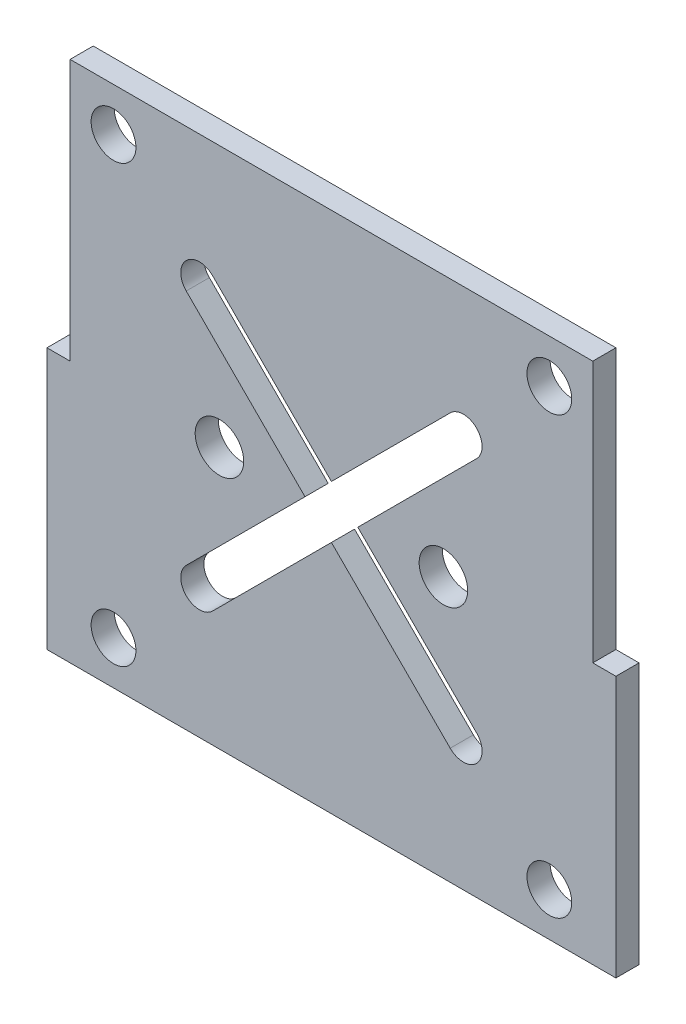
from build123d import *

# Parameters (mm, degrees)
SKETCH1_W           = 70
SKETCH1_H           = 70
SKETCH1_R           = 3
SKETCH1_R_2         = 3.25
BOSS_EXTRUDE1_DEPTH = 3.1
SKETCH2_W           = 3.1
SKETCH2_H           = 35
BOSS_EXTRUDE2_DEPTH = 3.1
CUT_EXTRUDE1_DEPTH  = 4.1


with BuildPart() as part:
    # Sketch1 → Boss-Extrude1 (new body)
    with BuildSketch(Plane.XY):
        Rectangle(SKETCH1_W, SKETCH1_H)
        with Locations((-29.185832393, 29.185832393)):
            Circle(SKETCH1_R, mode=Mode.SUBTRACT)
        with Locations((29.185832393, 29.185832393)):
            Circle(SKETCH1_R, mode=Mode.SUBTRACT)
        with Locations((29.185832393, -29.185832393)):
            Circle(SKETCH1_R, mode=Mode.SUBTRACT)
        with Locations((-29.185832393, -29.185832393)):
            Circle(SKETCH1_R, mode=Mode.SUBTRACT)
        with Locations((15, 0)):
            Circle(SKETCH1_R_2, mode=Mode.SUBTRACT)
        with Locations((-15, 0)):
            Circle(SKETCH1_R_2, mode=Mode.SUBTRACT)
    extrude(amount=BOSS_EXTRUDE1_DEPTH)

    # Sketch2 → Boss-Extrude2 (add, through all)
    with BuildSketch(Plane.XY.offset(3.1)):
        with Locations((36.55, -17.5)):
            Rectangle(SKETCH2_W, SKETCH2_H)
        with Locations((-36.55, -17.5)):
            Rectangle(SKETCH2_W, SKETCH2_H)
    extrude(amount=-BOSS_EXTRUDE2_DEPTH)

    # Sketch3 → Cut-Extrude1 (cut, through all)
    with BuildSketch(Plane.XY.offset(3.1)):
        with BuildLine():
            Line((-15.911823751, 19.447357657), (-0.001921175, 3.537455081))
            Line((-0.001921175, 3.537455081), (15.907981402, 19.447357657))
            ThreePointArc((15.907981402, 19.447357657), (19.443515308, 19.447357657), (19.443515308, 15.911823751))
            Line((19.443515308, 15.911823751), (3.533612731, 0.001921175))
            Line((3.533612731, 0.001921175), (19.443515308, -15.907981402))
            ThreePointArc((19.443515308, -15.907981402), (19.443515308, -19.443515308), (15.907981402, -19.443515308))
            Line((15.907981402, -19.443515308), (-0.001921175, -3.533612731))
            Line((-0.001921175, -3.533612731), (-15.911823751, -19.443515308))
            ThreePointArc((-15.911823751, -19.443515308), (-19.447357657, -19.443515308), (-19.447357657, -15.907981402))
            Line((-19.447357657, -15.907981402), (-3.537455081, 0.001921175))
            Line((-3.537455081, 0.001921175), (-19.447357657, 15.911823751))
            ThreePointArc((-19.447357657, 15.911823751), (-19.447357657, 19.447357657), (-15.911823751, 19.447357657))
        make_face()
    extrude(amount=-CUT_EXTRUDE1_DEPTH, mode=Mode.SUBTRACT)


solid = part.part
